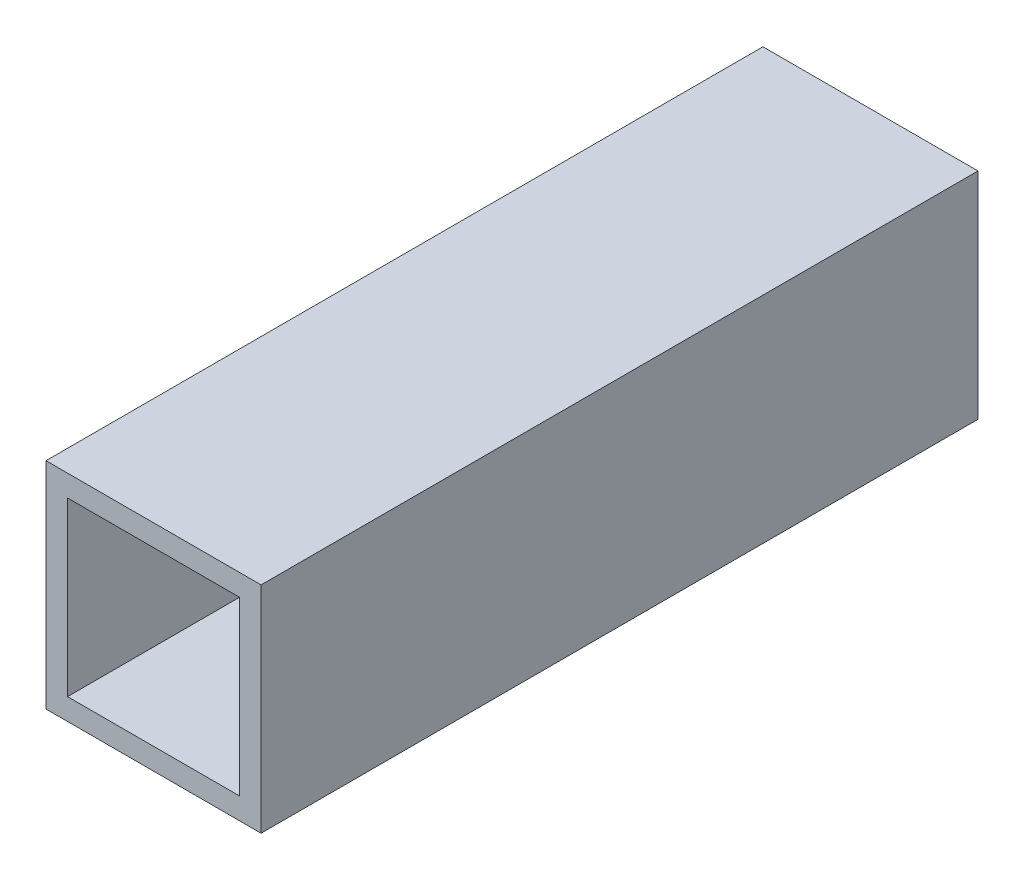
from build123d import *

# Parameters (mm, degrees)
SKETCH_1_W      = 15
SKETCH_1_H      = 15
SKETCH_1_W_2    = 12
SKETCH_1_H_2    = 12
EXTRUDE_2_DEPTH = 50


with BuildPart() as part:
    # ｽｹｯﾁ1 → ﾎﾞｽ - 押し出し2 (new body)
    with BuildSketch(Plane.XY):
        with Locations((0.489915859, 0.232626086)):
            Rectangle(SKETCH_1_W, SKETCH_1_H)
        with Locations((0.489915859, 0.232626086)):
            Rectangle(SKETCH_1_W_2, SKETCH_1_H_2, mode=Mode.SUBTRACT)
    extrude(amount=EXTRUDE_2_DEPTH)


solid = part.part
